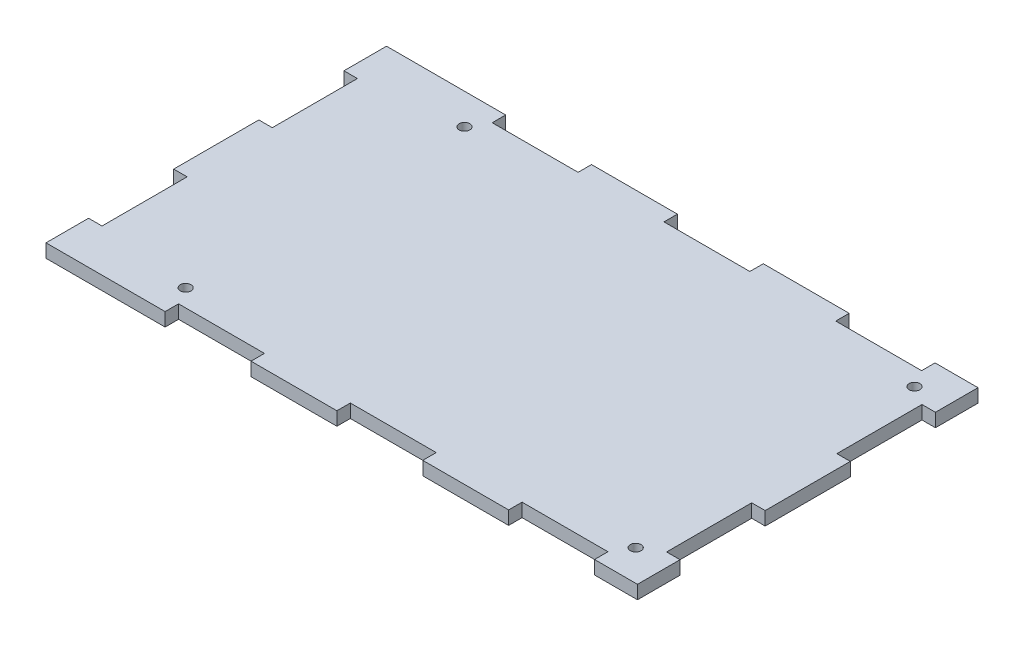
from build123d import *

# Parameters (mm, degrees)
CROQUIS1_W                 = 115
CROQUIS1_H                 = 76
SALIENTE_EXTRUIR1_DEPTH    = 1.5
CORTAR_EXTRUIR2_DEPTH      = 2.5
MATRIZL4_COUNT             = 3
MATRIZL4_PITCH             = 38.333333333
SIMETR_A1_COPY_1_DEPTH     = 2.5
SIMETR_A1_COPY_2_DEPTH     = 2.5
CORTAR_EXTRUIR3_DEPTH      = 2.5
MATRIZL5_COUNT             = 2
MATRIZL5_PITCH             = 38
SIMETR_A2_COPY_1_DEPTH     = 2.5
CROQUIS2_R                 = 1.2
CORTAR_EXTRUIR1_DEPTH      = 2.5
CORTAR_EXTRUIR1_DEPTH_BACK = 2.5
CROQUIS5_W                 = 9.5
CROQUIS5_H                 = 3
CROQUIS5_W_2               = 19
SALIENTE_EXTRUIR2_DEPTH    = 17
CROQUIS6_W                 = 19
CROQUIS6_H                 = 3
SALIENTE_EXTRUIR3_DEPTH    = 17


with BuildPart() as part:
    # Croquis1 → Saliente-Extruir1 (new body, symmetric)
    with BuildSketch(Plane(origin=(0, 0, 0), x_dir=(1, 0, 0), z_dir=(0, 1, 0))):
        Rectangle(CROQUIS1_W, CROQUIS1_H)
    extrude(amount=SALIENTE_EXTRUIR1_DEPTH, both=True)

    # Croquis3 → Cortar-Extruir2 (cut, symmetric)
    with BuildSketch(Plane(origin=(0, 0, 0), x_dir=(1, 0, 0), z_dir=(0, 1, 0))):
        Polygon((-47.916666667, -35), (-39.483333333, -35), (-37.183333333, -35), (-28.75, -35), (-28.75, -38), (-47.916666667, -38), align=None)
    cortar_extruir2 = extrude(amount=CORTAR_EXTRUIR2_DEPTH, both=True, mode=Mode.SUBTRACT)

    # MatrizL4: Cortar-Extruir2 ×3
    with Locations(*[(i * MATRIZL4_PITCH, 0, 0) for i in range(1, MATRIZL4_COUNT)]):
        add(cortar_extruir2, mode=Mode.SUBTRACT)

    # Simetría1: Cortar-Extruir2 across plane
    add(cortar_extruir2.mirror(Plane.XY), mode=Mode.SUBTRACT)

    # Simetría1 copy 1 sketch → Simetría1 copy 1 (cut, symmetric)
    with BuildSketch(Plane(origin=(38.333333333, 0, 0), x_dir=(1, 0, 0), z_dir=(0, 1, 0))):
        Polygon((-47.916666667, 35), (-39.483333333, 35), (-37.183333333, 35), (-28.75, 35), (-28.75, 38), (-47.916666667, 38), align=None)
    extrude(amount=SIMETR_A1_COPY_1_DEPTH, both=True, mode=Mode.SUBTRACT)

    # Simetría1 copy 2 sketch → Simetría1 copy 2 (cut, symmetric)
    with BuildSketch(Plane(origin=(76.666666667, 0, 0), x_dir=(1, 0, 0), z_dir=(0, 1, 0))):
        Polygon((-47.916666667, 35), (-39.483333333, 35), (-37.183333333, 35), (-28.75, 35), (-28.75, 38), (-47.916666667, 38), align=None)
    extrude(amount=SIMETR_A1_COPY_2_DEPTH, both=True, mode=Mode.SUBTRACT)

    # Croquis4 → Cortar-Extruir3 (cut, symmetric)
    with BuildSketch(Plane(origin=(0, 0, 0), x_dir=(1, 0, 0), z_dir=(0, 1, 0))):
        Polygon((-57.5, 28.5), (-54.5, 28.5), (-54.5, 20.15), (-54.5, 17.85), (-54.5, 9.5), (-57.5, 9.5), align=None)
    cortar_extruir3 = extrude(amount=CORTAR_EXTRUIR3_DEPTH, both=True, mode=Mode.SUBTRACT)

    # MatrizL5: Cortar-Extruir3 ×2
    with Locations(*[(0, 0, i * MATRIZL5_PITCH) for i in range(1, MATRIZL5_COUNT)]):
        add(cortar_extruir3, mode=Mode.SUBTRACT)

    # Simetría2: Cortar-Extruir3 across plane
    add(cortar_extruir3.mirror(Plane(origin=(0, 0, 0), x_dir=(0, 0, 1), z_dir=(1, 0, 0))), mode=Mode.SUBTRACT)

    # Simetría2 copy 1 sketch → Simetría2 copy 1 (cut, symmetric)
    with BuildSketch(Plane(origin=(0, 0, 38), x_dir=(-1, 0, 0), z_dir=(0, 1, 0))):
        Polygon((-57.5, -28.5), (-54.5, -28.5), (-54.5, -20.15), (-54.5, -17.85), (-54.5, -9.5), (-57.5, -9.5), align=None)
    extrude(amount=SIMETR_A2_COPY_1_DEPTH, both=True, mode=Mode.SUBTRACT)

    # Croquis2 → Cortar-Extruir1 (cut, two sides)
    with BuildSketch(Plane(origin=(0, 0, 0), x_dir=(1, 0, 0), z_dir=(0, 1, 0))) as cortar_extruir1_sk:
        with Locations((-50.22, 31.115)):
            Circle(CROQUIS2_R)
        with Locations((-50.22, -31.115)):
            Circle(CROQUIS2_R)
        with Locations((50.22, 31.115)):
            Circle(CROQUIS2_R)
        with Locations((50.22, -31.115)):
            Circle(CROQUIS2_R)
    extrude(amount=CORTAR_EXTRUIR1_DEPTH, mode=Mode.SUBTRACT)
    extrude(cortar_extruir1_sk.sketch, amount=-CORTAR_EXTRUIR1_DEPTH_BACK, mode=Mode.SUBTRACT)

    # Croquis5 → Saliente-Extruir2 (add)
    with BuildSketch(Plane.ZY.offset(57.5)):
        with Locations((-33.25, 0)):
            Rectangle(CROQUIS5_W, CROQUIS5_H)
        with Locations((33.25, 0)):
            Rectangle(CROQUIS5_W, CROQUIS5_H)
        Rectangle(CROQUIS5_W_2, CROQUIS5_H)
    extrude(amount=SALIENTE_EXTRUIR2_DEPTH)

    # Croquis6 → Saliente-Extruir3 (add)
    with BuildSketch(Plane.ZY.offset(54.5)):
        with Locations((19, 0)):
            Rectangle(CROQUIS6_W, CROQUIS6_H)
        with Locations((-19, 0)):
            Rectangle(CROQUIS6_W, CROQUIS6_H)
    extrude(amount=SALIENTE_EXTRUIR3_DEPTH)


solid = part.part
